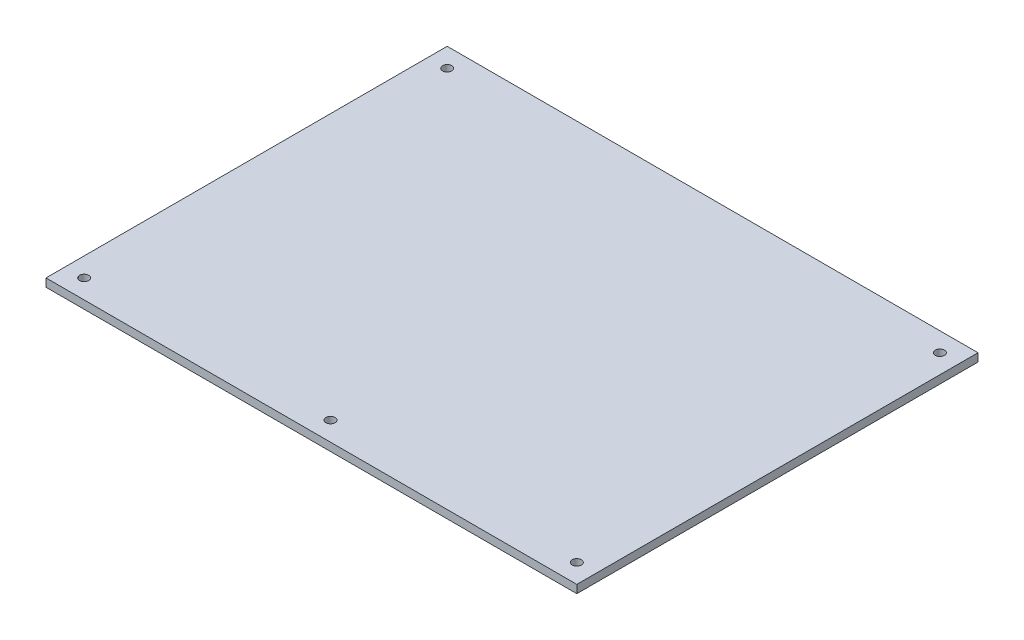
from build123d import *

# Parameters (mm, degrees)
SKETCH1_W           = 416.08
SKETCH1_H           = 314.48
BOSS_EXTRUDE1_DEPTH = 6.35
SKETCH2_R           = 3.6
CUT_EXTRUDE1_DEPTH  = 7.35


with BuildPart() as part:
    # Sketch1 → Boss-Extrude1 (new body)
    with BuildSketch(Plane(origin=(0, 0, 0), x_dir=(1, 0, 0), z_dir=(0, 1, 0))):
        with Locations((-38.07987983, -144.384858514)):
            Rectangle(SKETCH1_W, SKETCH1_H)
    extrude(amount=BOSS_EXTRUDE1_DEPTH)

    # Sketch2 → Cut-Extrude1 (cut, through all)
    with BuildSketch(Plane(origin=(0, 6.35, 0), x_dir=(1, 0, 0), z_dir=(0, 1, 0))):
        with Locations((-231.16987983, -2.094858514)):
            Circle(SKETCH2_R)
        with Locations((155.01012017, -2.094858514)):
            Circle(SKETCH2_R)
        with Locations((155.01012017, -286.674858514)):
            Circle(SKETCH2_R)
        with Locations((-38.07987983, -286.674858514)):
            Circle(SKETCH2_R)
        with Locations((-231.16987983, -286.674858514)):
            Circle(SKETCH2_R)
    extrude(amount=-CUT_EXTRUDE1_DEPTH, mode=Mode.SUBTRACT)


solid = part.part
